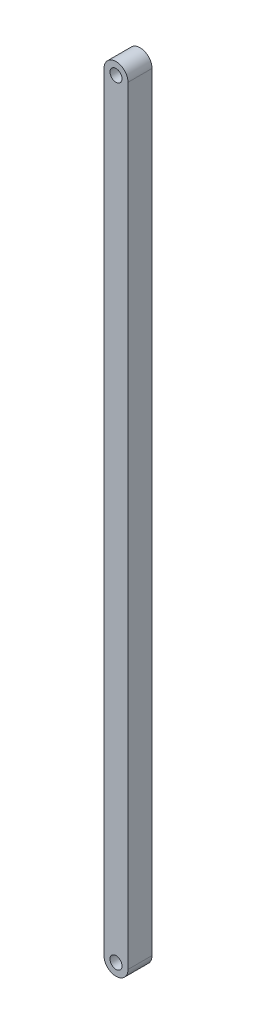
from build123d import *

# Parameters (mm, degrees)
ESQUISSE1_R        = 3.175
BOSS_EXTRU_1_DEPTH = 12.7


with BuildPart() as part:
    # Esquisse1 → Boss.-Extru.1 (new body)
    with BuildSketch(Plane.XY):
        with BuildLine():
            Line((0, 0), (0, 406.4))
            ThreePointArc((0, 406.4), (6.35, 412.75), (12.7, 406.4))
            Line((12.7, 406.4), (12.7, 0))
            ThreePointArc((12.7, 0), (6.35, -6.35), (0, 0))
        make_face()
        with Locations((6.35, 406.4)):
            Circle(ESQUISSE1_R, mode=Mode.SUBTRACT)
        with Locations((6.35, 0)):
            Circle(ESQUISSE1_R, mode=Mode.SUBTRACT)
    extrude(amount=BOSS_EXTRU_1_DEPTH)


solid = part.part
